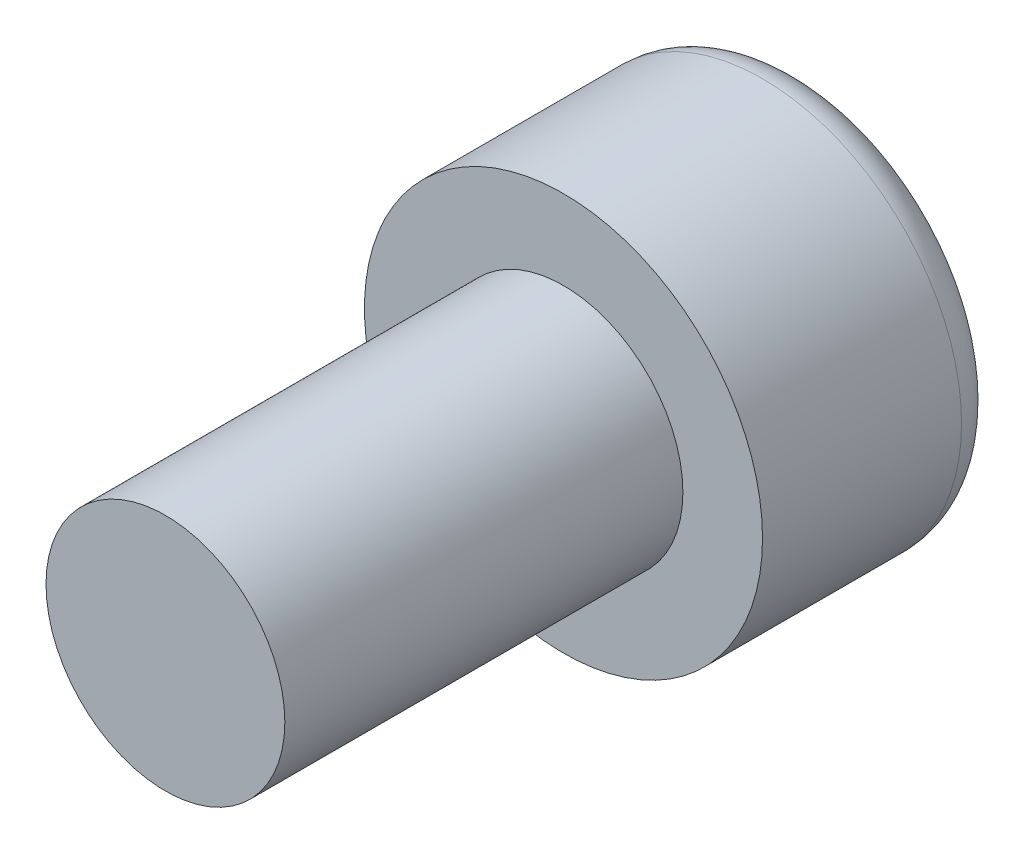
from build123d import *

# Parameters (mm, degrees)
SKETCH_1_R          = 5
EXTRUDE_1_DEPTH     = 6
SKETCH_2_R          = 3
EXTRUDE_2_DEPTH     = 10
CUT_EXTRUDE_1_DEPTH = 3
FILLET_1_R          = 1


with BuildPart() as part:
    # ｽｹｯﾁ1 → ﾎﾞｽ - 押し出し1 (new body)
    with BuildSketch(Plane.XY):
        Circle(SKETCH_1_R)
    extrude(amount=EXTRUDE_1_DEPTH)

    # ｽｹｯﾁ2 → ﾎﾞｽ - 押し出し2 (add)
    with BuildSketch(Plane.XY.offset(6)):
        Circle(SKETCH_2_R)
    extrude(amount=EXTRUDE_2_DEPTH)

    # ｽｹｯﾁ3 → ｶｯﾄ - 押し出し1 (cut)
    with BuildSketch(Plane(origin=(0, 0, 0), x_dir=(-1, 0, 0), z_dir=(0, 0, -1))):
        Polygon((-2.5, -1.443375673), (0, -2.886751346), (2.5, -1.443375673), (2.5, 1.443375673), (0, 2.886751346), (-2.5, 1.443375673), align=None)
    extrude(amount=-CUT_EXTRUDE_1_DEPTH, mode=Mode.SUBTRACT)

    # ﾌｨﾚｯﾄ1
    fillet_1_edges = [part.edges().sort_by_distance(p)[0] for p in [
        (-5, 0, 0),
    ]]
    fillet(fillet_1_edges, radius=FILLET_1_R)


solid = part.part
